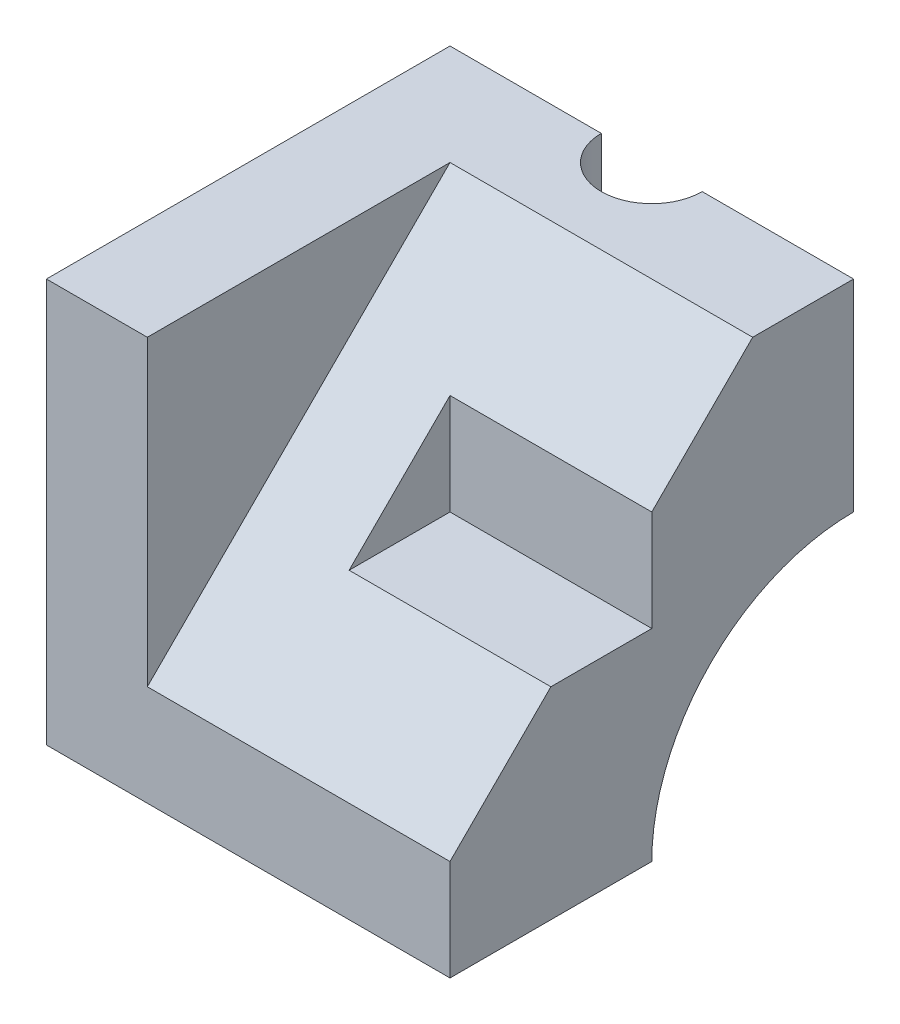
from build123d import *

# Parameters (mm, degrees)
SKETCH1_W           = 20
SKETCH1_H           = 80
BOSS_EXTRUDE1_DEPTH = 40
BOSS_EXTRUDE2_DEPTH = 80
CUT_EXTRUDE2_DEPTH  = 40
CUT_EXTRUDE4_DEPTH  = 81


with BuildPart() as part:
    # Sketch1 → Boss-Extrude1 (new body, symmetric)
    with BuildSketch(Plane.XY):
        with Locations((10, 40)):
            Rectangle(SKETCH1_W, SKETCH1_H)
    extrude(amount=BOSS_EXTRUDE1_DEPTH, both=True)

    # Sketch2 → Boss-Extrude2 (add)
    with BuildSketch(Plane(origin=(0, 0, 0), x_dir=(0, 0, -1), z_dir=(1, 0, 0))):
        with BuildLine():
            Line((40, 80), (20, 80))
            Line((20, 80), (-40, 20))
            Line((-40, 20), (-40, 0))
            Line((-40, 0), (0, 0))
            ThreePointArc((0, 0), (11.715728753, 28.284271247), (40, 40))
            Line((40, 40), (40, 80))
        make_face()
    extrude(amount=BOSS_EXTRUDE2_DEPTH)

    # Sketch4 → Cut-Extrude2 (cut)
    with BuildSketch(Plane(origin=(80, 0, 0), x_dir=(0, 0, -1), z_dir=(1, 0, 0))):
        Polygon((0, 60), (0, 40), (-20, 40), align=None)
    extrude(amount=-CUT_EXTRUDE2_DEPTH, mode=Mode.SUBTRACT)

    # Sketch5 → Cut-Extrude4 (cut, through all)
    with BuildSketch(Plane(origin=(0, 0, 0), x_dir=(1, 0, 0), z_dir=(0, 1, 0))):
        with BuildLine():
            Line((40, 40), (50, 40))
            ThreePointArc((50, 40), (40, 30), (30, 40))
            Line((30, 40), (40, 40))
        make_face()
    extrude(amount=CUT_EXTRUDE4_DEPTH, mode=Mode.SUBTRACT)


solid = part.part
